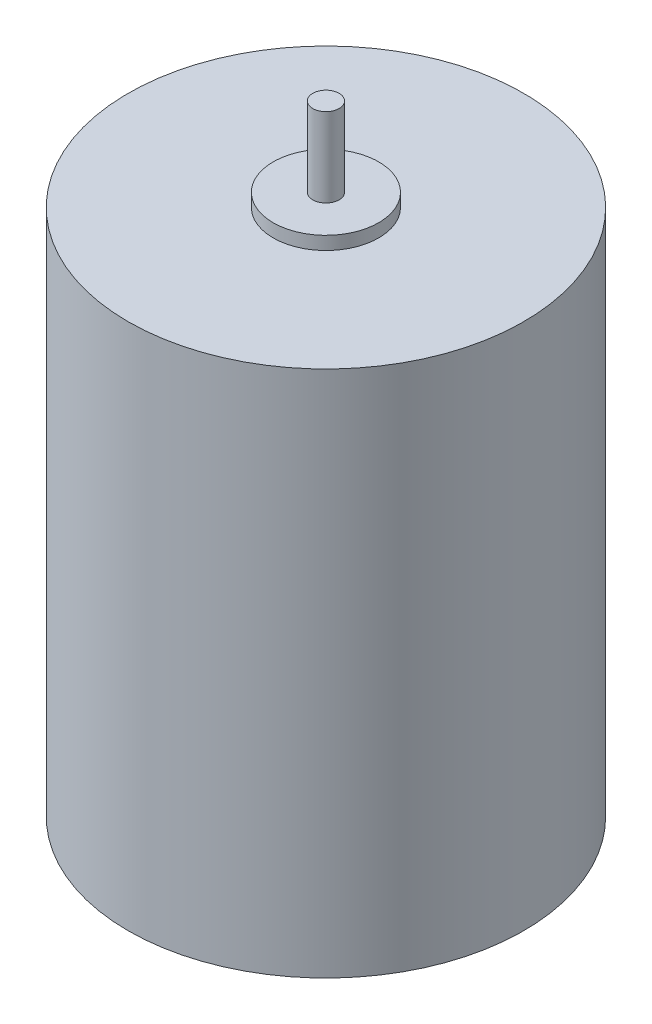
from build123d import *

# Parameters (mm, degrees)
ESQUISSE1_R      = 15
EXTRUSION1_DEPTH = 40
ESQUISSE2_R      = 4
EXTRUSION2_DEPTH = 1
ESQUISSE3_R      = 1
EXTRUSION3_DEPTH = 6


with BuildPart() as part:
    # Esquisse1 → Extrusion1 (new body)
    with BuildSketch(Plane(origin=(0, 0, 0), x_dir=(1, 0, 0), z_dir=(0, 1, 0))):
        Circle(ESQUISSE1_R)
    extrude(amount=EXTRUSION1_DEPTH)

    # Esquisse2 → Extrusion2 (add)
    with BuildSketch(Plane(origin=(0, 40, 0), x_dir=(1, 0, 0), z_dir=(0, 1, 0))):
        Circle(ESQUISSE2_R)
    extrude(amount=EXTRUSION2_DEPTH)

    # Esquisse3 → Extrusion3 (add)
    with BuildSketch(Plane(origin=(0, 41, 0), x_dir=(1, 0, 0), z_dir=(0, 1, 0))):
        Circle(ESQUISSE3_R)
    extrude(amount=EXTRUSION3_DEPTH)


solid = part.part
